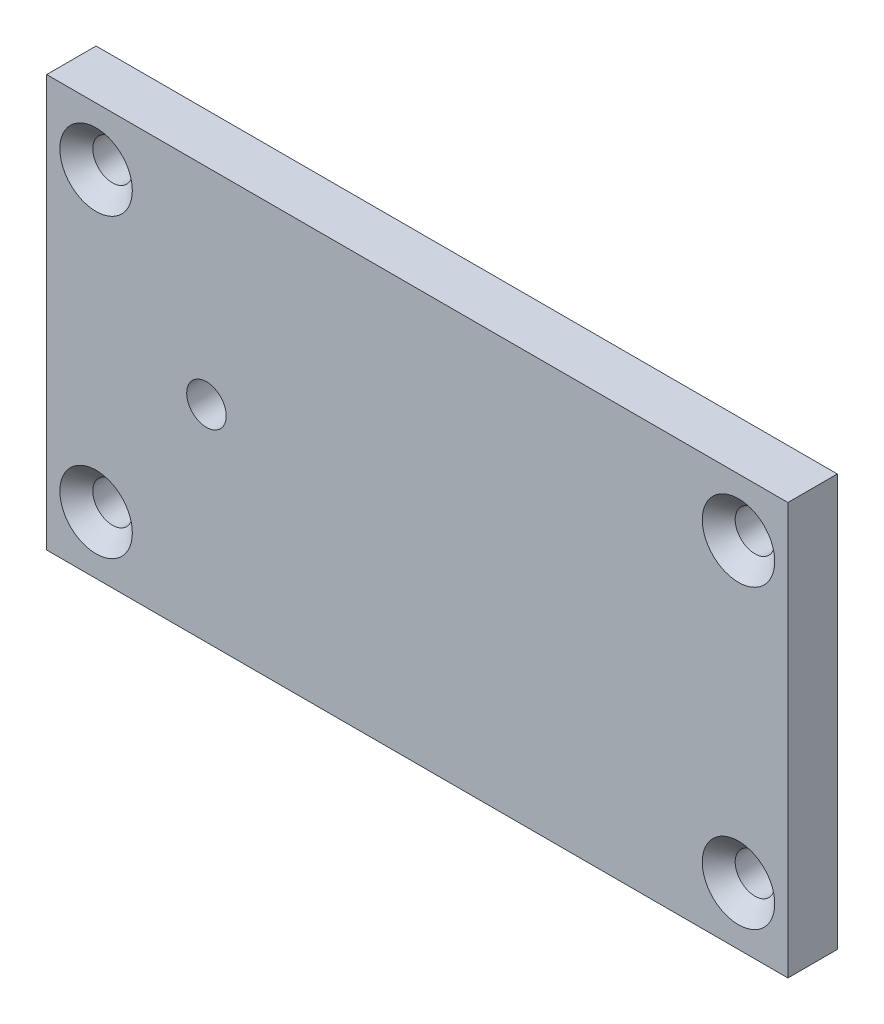
from build123d import *

# Parameters (mm, degrees)
SKETCH1_W                                       = 45
SKETCH1_H                                       = 25
BOSS_EXTRUDE1_DEPTH                             = 3
CSK_FOR_M2_FLAT_HEAD_MACHINE_SCREW1_D           = 2.4
CSK_FOR_M2_FLAT_HEAD_MACHINE_SCREW1_CSINK_D     = 4.4
CSK_FOR_M2_FLAT_HEAD_MACHINE_SCREW1_CSINK_ANGLE = 90
CSK_FOR_M2_FLAT_HEAD_MACHINE_SCREW2_D           = 2.4
CSK_FOR_M2_FLAT_HEAD_MACHINE_SCREW2_CSINK_D     = 4.4
CSK_FOR_M2_FLAT_HEAD_MACHINE_SCREW2_CSINK_ANGLE = 90


with BuildPart() as part:
    # Sketch1 → Boss-Extrude1 (new body)
    with BuildSketch(Plane.XY):
        Rectangle(SKETCH1_W, SKETCH1_H)
    extrude(amount=BOSS_EXTRUDE1_DEPTH)

    # CSK for M2 Flat Head Machine Screw1 (through all)
    with Locations(Plane.XY.offset(3)):
        with Locations((-19.5, 9), (19.5, 9), (19.5, -9), (-19.5, -9)):
            CounterSinkHole(CSK_FOR_M2_FLAT_HEAD_MACHINE_SCREW1_D / 2, CSK_FOR_M2_FLAT_HEAD_MACHINE_SCREW1_CSINK_D / 2, counter_sink_angle=CSK_FOR_M2_FLAT_HEAD_MACHINE_SCREW1_CSINK_ANGLE)

    # CSK for M2 Flat Head Machine Screw2 (through all)
    with Locations(Plane(origin=(0, 0, 0), x_dir=(-1, 0, 0), z_dir=(0, 0, -1))):
        with Locations((12.8, 0)):
            CounterSinkHole(CSK_FOR_M2_FLAT_HEAD_MACHINE_SCREW2_D / 2, CSK_FOR_M2_FLAT_HEAD_MACHINE_SCREW2_CSINK_D / 2, counter_sink_angle=CSK_FOR_M2_FLAT_HEAD_MACHINE_SCREW2_CSINK_ANGLE)


solid = part.part
